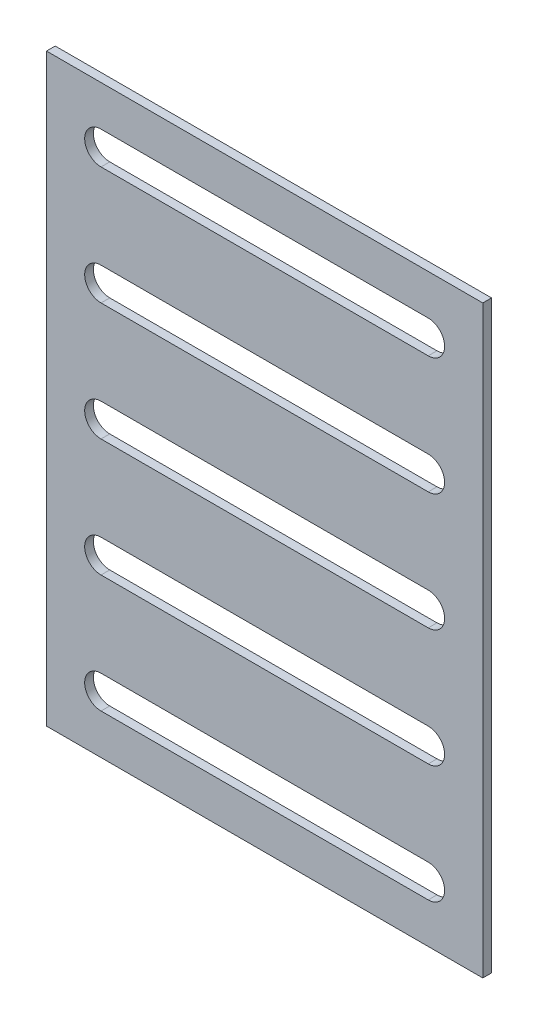
from build123d import *

# Parameters (mm, degrees)
SKETCH_1_W          = 200
SKETCH_1_H          = 268
EXTRUDE_1_DEPTH     = 4
CUT_EXTRUDE_1_DEPTH = 5


with BuildPart() as part:
    # 草图1 → 凸台-拉伸1 (new body)
    with BuildSketch(Plane.XY):
        Rectangle(SKETCH_1_W, SKETCH_1_H)
    extrude(amount=EXTRUDE_1_DEPTH)

    # 草图2 → 切除-拉伸1 (cut, through all)
    with BuildSketch(Plane.XY.offset(4)):
        with BuildLine():
            Line((-75, 115.5), (75, 115.5))
            ThreePointArc((75, 115.5), (82.5, 108), (75, 100.5))
            Line((75, 100.5), (-75, 100.5))
            ThreePointArc((-75, 100.5), (-82.5, 108), (-75, 115.5))
        make_face()
        with BuildLine():
            Line((-75, 61.5), (75, 61.5))
            ThreePointArc((75, 61.5), (82.5, 54), (75, 46.5))
            Line((75, 46.5), (-75, 46.5))
            ThreePointArc((-75, 46.5), (-82.5, 54), (-75, 61.5))
        make_face()
        with BuildLine():
            Line((-75, 7.5), (75, 7.5))
            ThreePointArc((75, 7.5), (82.5, 0), (75, -7.5))
            Line((75, -7.5), (-75, -7.5))
            ThreePointArc((-75, -7.5), (-82.5, 0), (-75, 7.5))
        make_face()
        with BuildLine():
            Line((-75, -46.5), (75, -46.5))
            ThreePointArc((75, -46.5), (82.5, -54), (75, -61.5))
            Line((75, -61.5), (-75, -61.5))
            ThreePointArc((-75, -61.5), (-82.5, -54), (-75, -46.5))
        make_face()
        with BuildLine():
            Line((-75, -100.5), (75, -100.5))
            ThreePointArc((75, -100.5), (82.5, -108), (75, -115.5))
            Line((75, -115.5), (-75, -115.5))
            ThreePointArc((-75, -115.5), (-82.5, -108), (-75, -100.5))
        make_face()
    extrude(amount=-CUT_EXTRUDE_1_DEPTH, mode=Mode.SUBTRACT)


solid = part.part
